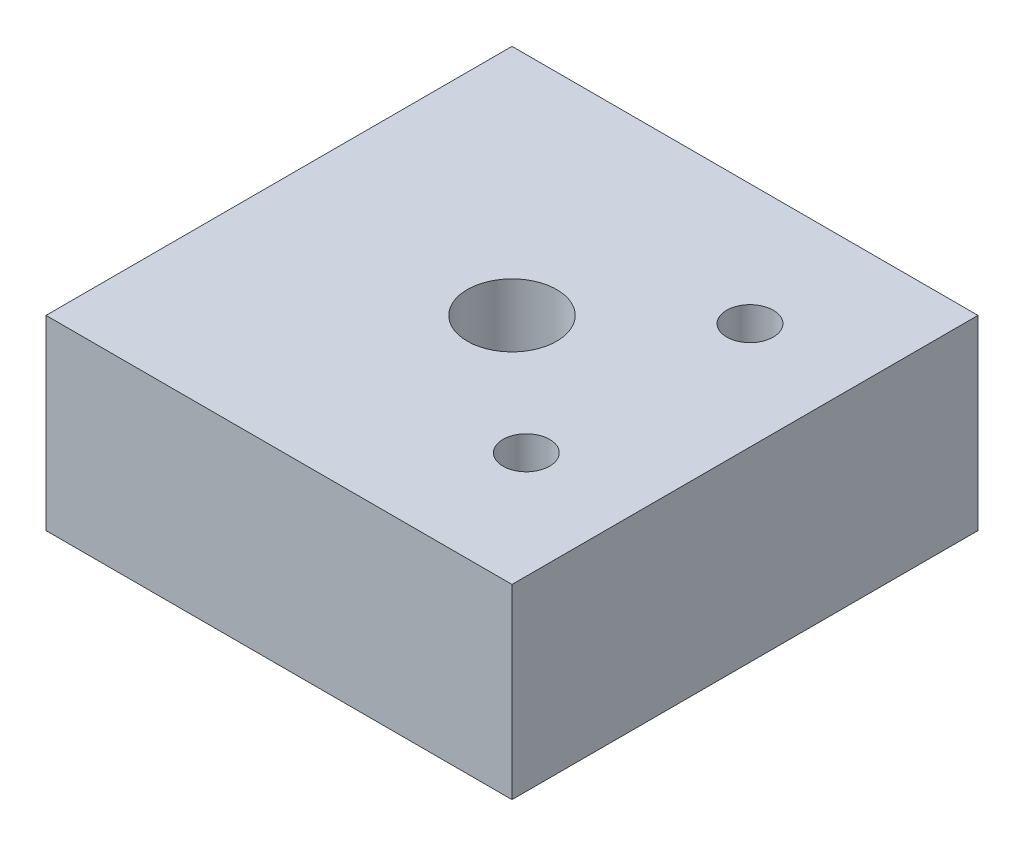
from build123d import *

# Parameters (mm, degrees)
SKETCH1_W           = 500
SKETCH1_H           = 500
SKETCH1_R           = 48.019392693
SKETCH1_R_2         = 25
BOSS_EXTRUDE1_DEPTH = 200


with BuildPart() as part:
    # Sketch1 → Boss-Extrude1 (new body)
    with BuildSketch(Plane(origin=(0, 0, 0), x_dir=(1, 0, 0), z_dir=(0, 1, 0))):
        Rectangle(SKETCH1_W, SKETCH1_H)
        Circle(SKETCH1_R, mode=Mode.SUBTRACT)
        with Locations((135.356868742, 120)):
            Circle(SKETCH1_R_2, mode=Mode.SUBTRACT)
        with Locations((135.356868742, -120)):
            Circle(SKETCH1_R_2, mode=Mode.SUBTRACT)
    extrude(amount=BOSS_EXTRUDE1_DEPTH)


solid = part.part
